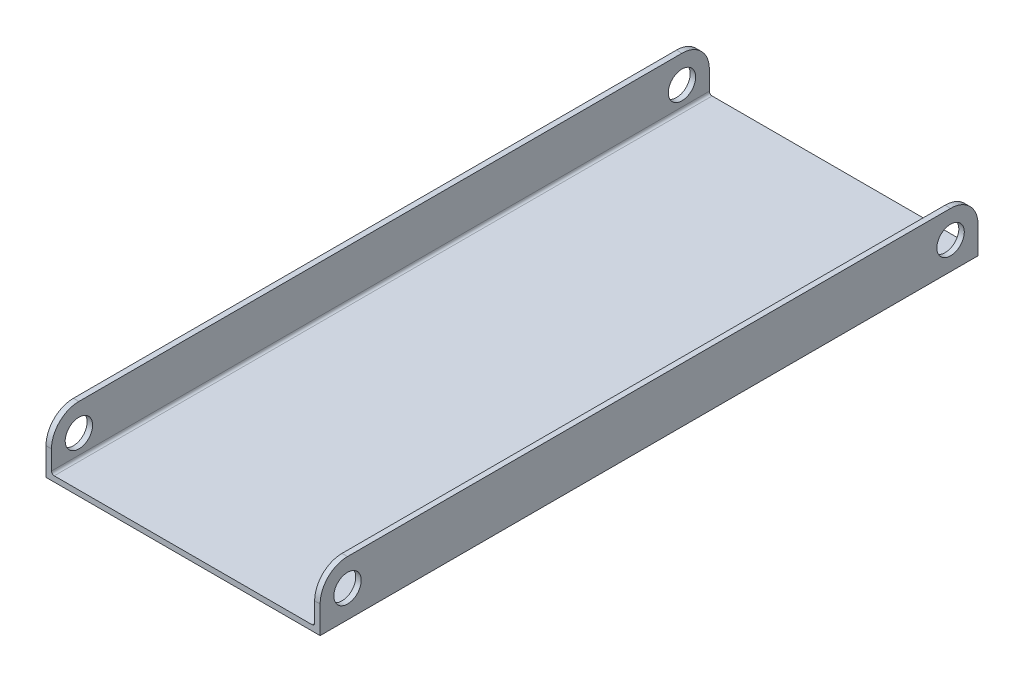
from build123d import *

# Parameters (mm, degrees)
BOSS_EXTRUDE1_DEPTH = 152.4
FILLET1_R           = 6.35
SKETCH2_R           = 3.175
CUT_EXTRUDE1_DEPTH  = 64.5


with BuildPart() as part:
    # Sketch1 → Boss-Extrude1 (new body)
    with BuildSketch(Plane.XY):
        with BuildLine():
            Line((-30.48, 11.43), (-30.48, 0.635))
            ThreePointArc((-30.48, 0.635), (-30.294012806, 0.185987194), (-29.845, 0))
            Line((-29.845, 0), (29.845, 0))
            ThreePointArc((29.845, 0), (30.294012806, 0.185987194), (30.48, 0.635))
            Line((30.48, 0.635), (30.48, 11.43))
            Line((30.48, 11.43), (31.75, 11.43))
            Line((31.75, 11.43), (31.75, -1.27))
            Line((31.75, -1.27), (-31.75, -1.27))
            Line((-31.75, -1.27), (-31.75, 11.43))
            Line((-31.75, 11.43), (-30.48, 11.43))
        make_face()
    extrude(amount=-BOSS_EXTRUDE1_DEPTH)

    # Fillet1
    fillet1_edges = [part.edges().sort_by_distance(p)[0] for p in [
        (31.115, 11.43, 0),
        (-31.115, 11.43, 0),
        (31.115, 11.43, -152.4),
        (-31.115, 11.43, -152.4),
    ]]
    fillet(fillet1_edges, radius=FILLET1_R)

    # Sketch2 → Cut-Extrude1 (cut, through all)
    with BuildSketch(Plane(origin=(31.75, 0, 0), x_dir=(0, 0, -1), z_dir=(1, 0, 0))):
        with Locations((6.35, 5.08)):
            Circle(SKETCH2_R)
        with Locations((146.05, 5.08)):
            Circle(SKETCH2_R)
    extrude(amount=-CUT_EXTRUDE1_DEPTH, mode=Mode.SUBTRACT)


solid = part.part
